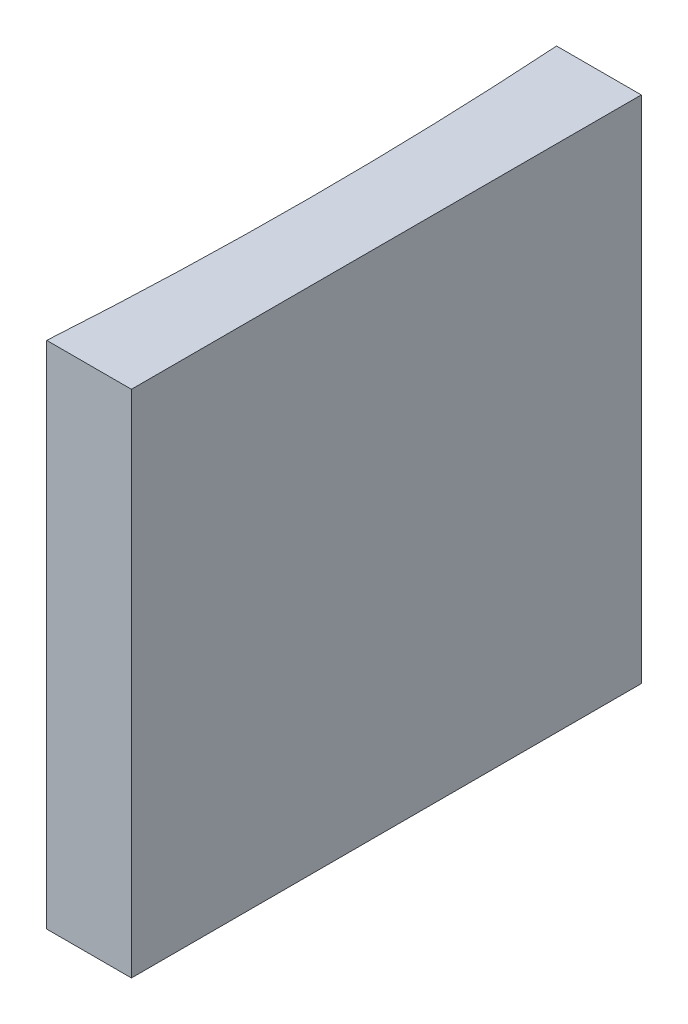
from build123d import *

# Parameters (mm, degrees)
EXTRUDE_1_DEPTH = 20


with BuildPart() as part:
    # 草图1 → 凸台-拉伸1 (new body)
    with BuildSketch(Plane(origin=(0, 0, 0), x_dir=(1, 0, 0), z_dir=(0, 1, 0))):
        with BuildLine():
            Line((0, 0), (0, -20))
            Line((0, -20), (-3.322708384, -20))
            ThreePointArc((-3.322708384, -20), (-3, -10), (-3.322708384, 0))
            Line((-3.322708384, 0), (0, 0))
        make_face()
    extrude(amount=EXTRUDE_1_DEPTH)


solid = part.part
